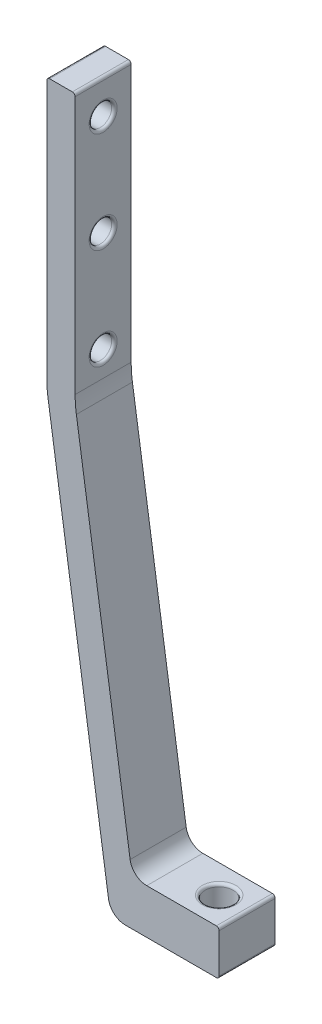
from build123d import *

# Parameters (mm, degrees)
BOSS_EXTRUDE1_DEPTH = 5
SKETCH3_R           = 2.5
CUT_EXTRUDE1_DEPTH  = 10
CUT_EXTRUDE2_REACH  = 7.056
SKETCH4_R           = 2
FILLET1_R           = 3
FILLET2_R           = 0.5
FILLET3_R           = 20


with BuildPart() as part:
    # Sketch1 → Boss-Extrude1 (new body, symmetric)
    with BuildSketch(Plane.XY):
        Polygon((-27, 0), (-46.356564011, 0), (-57.75, 76), (-57.75, 124), (-52.694126938, 124), (-52.694126938, 76), (-42.5, 8), (-27, 8), align=None)
    extrude(amount=BOSS_EXTRUDE1_DEPTH, both=True)

    # Sketch3 → Cut-Extrude1 (cut)
    with BuildSketch(Plane(origin=(0, 8, 0), x_dir=(1, 0, 0), z_dir=(0, 1, 0))):
        with Locations((-32, 0)):
            Circle(SKETCH3_R)
    extrude(amount=-CUT_EXTRUDE1_DEPTH, mode=Mode.SUBTRACT)

    # Sketch4 → Cut-Extrude2 (cut, up to next)
    with BuildSketch(Plane(origin=(-52.694126938, 0, 0), x_dir=(0, 0, -1), z_dir=(1, 0, 0)), mode=Mode.PRIVATE) as cut_extrude2_sk1:
        with Locations((0, 100)):
            Circle(SKETCH4_R)
    cut_extrude2_tool1 = extrude(cut_extrude2_sk1.sketch, amount=-CUT_EXTRUDE2_REACH, mode=Mode.PRIVATE) & part.part
    add(cut_extrude2_tool1.solids().sort_by_distance((-52.694127, 100, 0))[0], mode=Mode.SUBTRACT)
    # Sketch4 → Cut-Extrude2 (cut, up to next)
    with BuildSketch(Plane(origin=(-52.694126938, 0, 0), x_dir=(0, 0, -1), z_dir=(1, 0, 0)), mode=Mode.PRIVATE) as cut_extrude2_sk2:
        with Locations((0, 82)):
            Circle(SKETCH4_R)
    cut_extrude2_tool2 = extrude(cut_extrude2_sk2.sketch, amount=-CUT_EXTRUDE2_REACH, mode=Mode.PRIVATE) & part.part
    add(cut_extrude2_tool2.solids().sort_by_distance((-52.694127, 82, 0))[0], mode=Mode.SUBTRACT)
    # Sketch4 → Cut-Extrude2 (cut, up to next)
    with BuildSketch(Plane(origin=(-52.694126938, 0, 0), x_dir=(0, 0, -1), z_dir=(1, 0, 0)), mode=Mode.PRIVATE) as cut_extrude2_sk3:
        with Locations((0, 118)):
            Circle(SKETCH4_R)
    cut_extrude2_tool3 = extrude(cut_extrude2_sk3.sketch, amount=-CUT_EXTRUDE2_REACH, mode=Mode.PRIVATE) & part.part
    add(cut_extrude2_tool3.solids().sort_by_distance((-52.694127, 118, 0))[0], mode=Mode.SUBTRACT)

    # Fillet1
    fillet1_edges = [part.edges().sort_by_distance(p)[0] for p in [
        (-46.356564011, 0, 0),
        (-42.5, 8, 0),
    ]]
    fillet(fillet1_edges, radius=FILLET1_R)

    # Fillet2
    fillet2_edges = [part.edges().sort_by_distance(p)[0] for p in [
        (-27, 0, 0),
        (-57.75, 124, 0),
        (-52.694126938, 124, 0),
        (-27, 8, 0),
        (-34.5, 0, 0),
        (-34.5, 8, 0),
        (-52.694126938, 82, 2),
        (-57.75, 82, 2),
        (-52.694126938, 118, 2),
        (-57.75, 118, 2),
        (-52.694126938, 100, 2),
        (-57.75, 100, 2),
    ]]
    fillet(fillet2_edges, radius=FILLET2_R)

    # Fillet3
    fillet3_edges = [part.edges().sort_by_distance(p)[0] for p in [
        (-57.75, 76, 0),
        (-52.694126938, 76, 0),
    ]]
    fillet(fillet3_edges, radius=FILLET3_R)


solid = part.part
